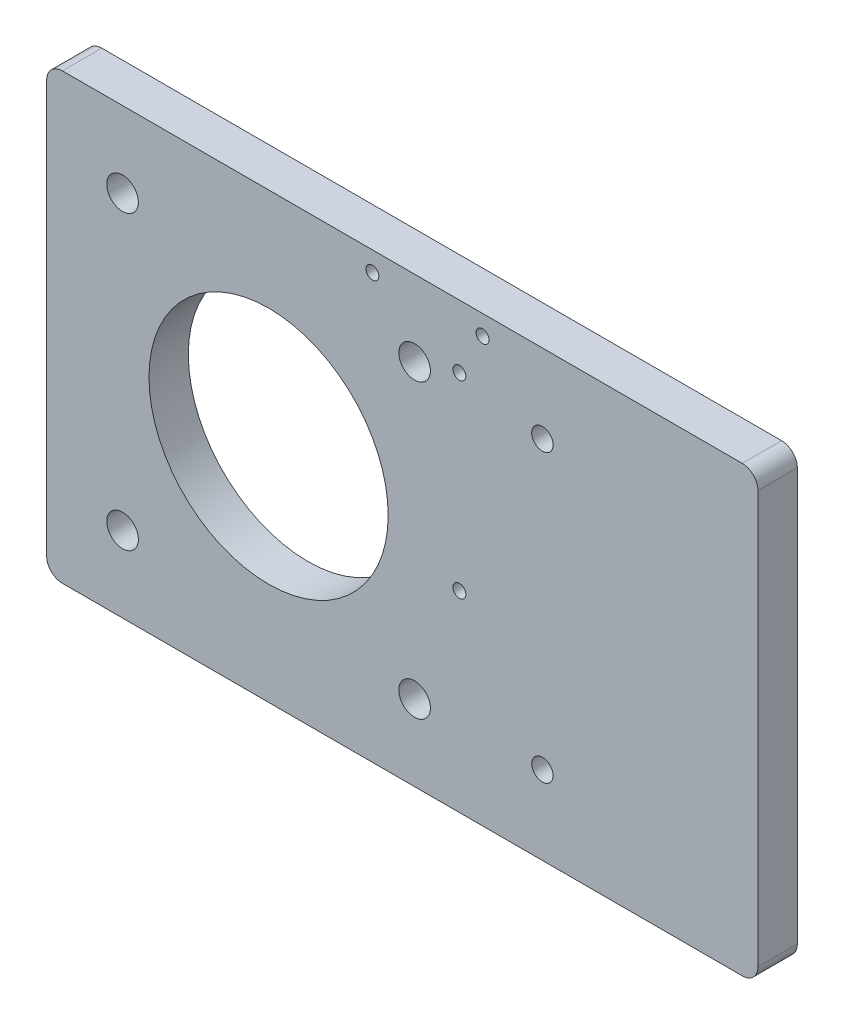
from build123d import *

# Parameters (mm, degrees)
SKETCH3_R                     = 19.304
SKETCH3_R_2                   = 2.55
BOSS_EXTRUDE1_DEPTH           = 6.35
TAP_DRILL_FOR_3_56_TAP1_D     = 2.0828
TAP_DRILL_FOR_3_56_TAP1_DEPTH = 7.62
TAP_DRILL_FOR_3_56_TAP1_TIP   = 0.625736249
TAP_DRILL_FOR_8_32_TAP2_D     = 3.4544


with BuildPart() as part:
    # Sketch3 → Boss-Extrude1 (new body)
    with BuildSketch(Plane.XY):
        with BuildLine():
            Line((-33.28, 35.82), (76.46, 35.82))
            ThreePointArc((76.46, 35.82), (78.256051224, 35.076051224), (79, 33.28))
            Line((79, 33.28), (79, -33.28))
            ThreePointArc((79, -33.28), (78.256051224, -35.076051224), (76.46, -35.82))
            Line((76.46, -35.82), (-33.28, -35.82))
            ThreePointArc((-33.28, -35.82), (-35.076051224, -35.076051224), (-35.82, -33.28))
            Line((-35.82, -33.28), (-35.82, 33.28))
            ThreePointArc((-35.82, 33.28), (-35.076051224, 35.076051224), (-33.28, 35.82))
        make_face()
        Circle(SKETCH3_R, mode=Mode.SUBTRACT)
        with Locations((23.57, 23.57)):
            Circle(SKETCH3_R_2, mode=Mode.SUBTRACT)
        with Locations((-23.57, 23.57)):
            Circle(SKETCH3_R_2, mode=Mode.SUBTRACT)
        with Locations((-23.57, -23.57)):
            Circle(SKETCH3_R_2, mode=Mode.SUBTRACT)
        with Locations((23.57, -23.57)):
            Circle(SKETCH3_R_2, mode=Mode.SUBTRACT)
    extrude(amount=BOSS_EXTRUDE1_DEPTH)

    # Tap Drill for #3-56 Tap1
    with Locations(Plane(origin=(0, 0, 6.35), x_dir=(-1, 0, 0), z_dir=(0, 0, 1))):
        with Locations((-30.8029, 4.82), (-34.544, -32.645), (-16.764, -32.645), (-30.8029, -25.66)):
            Hole(TAP_DRILL_FOR_3_56_TAP1_D / 2, depth=TAP_DRILL_FOR_3_56_TAP1_DEPTH)
            with Locations((0, 0, -(TAP_DRILL_FOR_3_56_TAP1_DEPTH + TAP_DRILL_FOR_3_56_TAP1_TIP / 2))):  # 118° drill point
                Cone(0, TAP_DRILL_FOR_3_56_TAP1_D / 2, TAP_DRILL_FOR_3_56_TAP1_TIP, mode=Mode.SUBTRACT)

    # Tap Drill for #8-32 Tap2 (through all)
    with Locations(Plane(origin=(0, 0, 0), x_dir=(-1, 0, 0), z_dir=(0, 0, -1))):
        with Locations((-44.202, 23.12), (-44.202, -23.12)):
            Hole(TAP_DRILL_FOR_8_32_TAP2_D / 2)


solid = part.part
